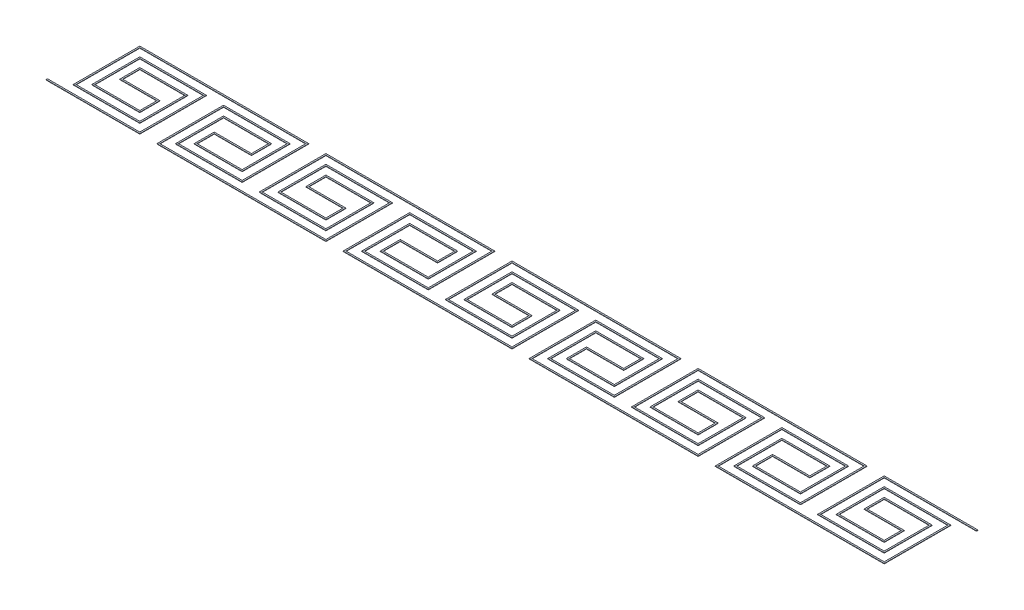
from build123d import *

# Parameters (mm, degrees)
SKETCH2_W = 0.02
SKETCH2_H = 0.005


with BuildPart() as part:
    # Sweep1: sweep along a path in Sketch1
    with BuildLine(Plane(origin=(0, 0, 0), x_dir=(1, 0, 0), z_dir=(0, 1, 0))) as sweep1_path:
        Line((0.75, 0.5), (0.5, 0.5))
        Line((0.5, 0.5), (-0.5, 0.5))
        Line((-0.5, 0.5), (-0.5, -0.375))
        Line((-0.5, -0.375), (0.375, -0.375))
        Line((0.375, -0.375), (0.375, 0.25))
        Line((0.375, 0.25), (-0.25, 0.25))
        Line((-0.25, 0.25), (-0.25, 0))
        Line((-0.25, 0), (0.25, 0))
        Line((0.25, 0), (0.25, -0.25))
        Line((0.25, -0.25), (-0.375, -0.25))
        Line((-0.375, -0.25), (-0.375, 0.375))
        Line((-0.375, 0.375), (0.5, 0.375))
        Line((0.5, 0.375), (0.5, -0.5))
        Line((0.5, -0.5), (-0.5, -0.5))
        Line((-0.5, -0.5), (-0.75, -0.5))
        Line((-0.75, -0.5), (-1.75, -0.5))
        Line((-1.75, -0.5), (-1.75, 0.375))
        Line((-1.75, 0.375), (-0.875, 0.375))
        Line((-0.875, 0.375), (-0.875, -0.25))
        Line((-0.875, -0.25), (-1.5, -0.25))
        Line((-1.5, -0.25), (-1.5, 0))
        Line((-1.5, 0), (-1, 0))
        Line((-1, 0), (-1, 0.25))
        Line((-1, 0.25), (-1.625, 0.25))
        Line((-1.625, 0.25), (-1.625, -0.375))
        Line((-1.625, -0.375), (-0.75, -0.375))
        Line((-0.75, -0.375), (-0.75, 0.5))
        Line((-0.75, 0.5), (-1.75, 0.5))
        Line((-1.75, 0.5), (-2, 0.5))
        Line((-2, 0.5), (-3, 0.5))
        Line((-3, 0.5), (-3, -0.375))
        Line((-3, -0.375), (-2.125, -0.375))
        Line((-2.125, -0.375), (-2.125, 0.25))
        Line((-2.125, 0.25), (-2.75, 0.25))
        Line((-2.75, 0.25), (-2.75, 0))
        Line((-2.75, 0), (-2.25, 0))
        Line((-2.25, 0), (-2.25, -0.25))
        Line((-2.25, -0.25), (-2.875, -0.25))
        Line((-2.875, -0.25), (-2.875, 0.375))
        Line((-2.875, 0.375), (-2, 0.375))
        Line((-2, 0.375), (-2, -0.5))
        Line((-2, -0.5), (-3, -0.5))
        Line((-3, -0.5), (-3.25, -0.5))
        Line((-3.25, -0.5), (-4.25, -0.5))
        Line((-4.25, -0.5), (-4.25, 0.375))
        Line((-4.25, 0.375), (-3.375, 0.375))
        Line((-3.375, 0.375), (-3.375, -0.25))
        Line((-3.375, -0.25), (-4, -0.25))
        Line((-4, -0.25), (-4, 0))
        Line((-4, 0), (-3.5, 0))
        Line((-3.5, 0), (-3.5, 0.25))
        Line((-3.5, 0.25), (-4.125, 0.25))
        Line((-4.125, 0.25), (-4.125, -0.375))
        Line((-4.125, -0.375), (-3.25, -0.375))
        Line((-3.25, -0.375), (-3.25, 0.5))
        Line((-3.25, 0.5), (-4.25, 0.5))
        Line((-4.25, 0.5), (-4.5, 0.5))
        Line((-4.5, 0.5), (-5.5, 0.5))
        Line((-5.5, 0.5), (-5.5, -0.375))
        Line((-5.5, -0.375), (-4.625, -0.375))
        Line((-4.625, -0.375), (-4.625, 0.25))
        Line((-4.625, 0.25), (-5.25, 0.25))
        Line((-5.25, 0.25), (-5.25, 0))
        Line((-5.25, 0), (-4.75, 0))
        Line((-4.75, 0), (-4.75, -0.25))
        Line((-4.75, -0.25), (-5.375, -0.25))
        Line((-5.375, -0.25), (-5.375, 0.375))
        Line((-5.375, 0.375), (-4.5, 0.375))
        Line((-4.5, 0.375), (-4.5, -0.5))
        Line((-4.5, -0.5), (-5.5, -0.5))
        Line((-5.5, -0.5), (-5.75, -0.5))
        Line((-5.75, -0.5), (-6.75, -0.5))
        Line((-6.75, -0.5), (-6.75, 0.375))
        Line((-6.75, 0.375), (-5.875, 0.375))
        Line((-5.875, 0.375), (-5.875, -0.25))
        Line((-5.875, -0.25), (-6.5, -0.25))
        Line((-6.5, -0.25), (-6.5, 0))
        Line((-6.5, 0), (-6, 0))
        Line((-6, 0), (-6, 0.25))
        Line((-6, 0.25), (-6.625, 0.25))
        Line((-6.625, 0.25), (-6.625, -0.375))
        Line((-6.625, -0.375), (-5.75, -0.375))
        Line((-5.75, -0.375), (-5.75, 0.5))
        Line((-5.75, 0.5), (-6.75, 0.5))
        Line((-6.75, 0.5), (-7, 0.5))
        Line((-7, 0.5), (-8, 0.5))
        Line((-8, 0.5), (-8, -0.375))
        Line((-8, -0.375), (-7.125, -0.375))
        Line((-7.125, -0.375), (-7.125, 0.25))
        Line((-7.125, 0.25), (-7.75, 0.25))
        Line((-7.75, 0.25), (-7.75, 0))
        Line((-7.75, 0), (-7.25, 0))
        Line((-7.25, 0), (-7.25, -0.25))
        Line((-7.25, -0.25), (-7.875, -0.25))
        Line((-7.875, -0.25), (-7.875, 0.375))
        Line((-7.875, 0.375), (-7, 0.375))
        Line((-7, 0.375), (-7, -0.5))
        Line((-7, -0.5), (-8, -0.5))
        Line((-8, -0.5), (-8.25, -0.5))
        Line((-8.25, -0.5), (-9.25, -0.5))
        Line((-9.25, -0.5), (-9.25, 0.375))
        Line((-9.25, 0.375), (-8.375, 0.375))
        Line((-8.375, 0.375), (-8.375, -0.25))
        Line((-8.375, -0.25), (-9, -0.25))
        Line((-9, -0.25), (-9, 0))
        Line((-9, 0), (-8.5, 0))
        Line((-8.5, 0), (-8.5, 0.25))
        Line((-8.5, 0.25), (-9.125, 0.25))
        Line((-9.125, 0.25), (-9.125, -0.375))
        Line((-9.125, -0.375), (-8.25, -0.375))
        Line((-8.25, -0.375), (-8.25, 0.5))
        Line((-8.25, 0.5), (-9.25, 0.5))
        Line((-9.25, 0.5), (-9.5, 0.5))
        Line((-9.5, 0.5), (-10.5, 0.5))
        Line((-10.5, 0.5), (-10.5, -0.375))
        Line((-10.5, -0.375), (-9.625, -0.375))
        Line((-9.625, -0.375), (-9.625, 0.25))
        Line((-9.625, 0.25), (-10.25, 0.25))
        Line((-10.25, 0.25), (-10.25, 0))
        Line((-10.25, 0), (-9.75, 0))
        Line((-9.75, 0), (-9.75, -0.25))
        Line((-9.75, -0.25), (-10.375, -0.25))
        Line((-10.375, -0.25), (-10.375, 0.375))
        Line((-10.375, 0.375), (-9.5, 0.375))
        Line((-9.5, 0.375), (-9.5, -0.5))
        Line((-9.5, -0.5), (-10.5, -0.5))
        Line((-10.5, -0.5), (-10.75, -0.5))
    # Sketch2 → Sweep1 (sweep)
    with BuildSketch(Plane(origin=(0, 0, 0), x_dir=(0, 0, -1), z_dir=(1, 0, 0))):
        Rectangle(SKETCH2_W, SKETCH2_H)
    sweep(path=sweep1_path.line, transition=Transition.RIGHT)


solid = part.part
